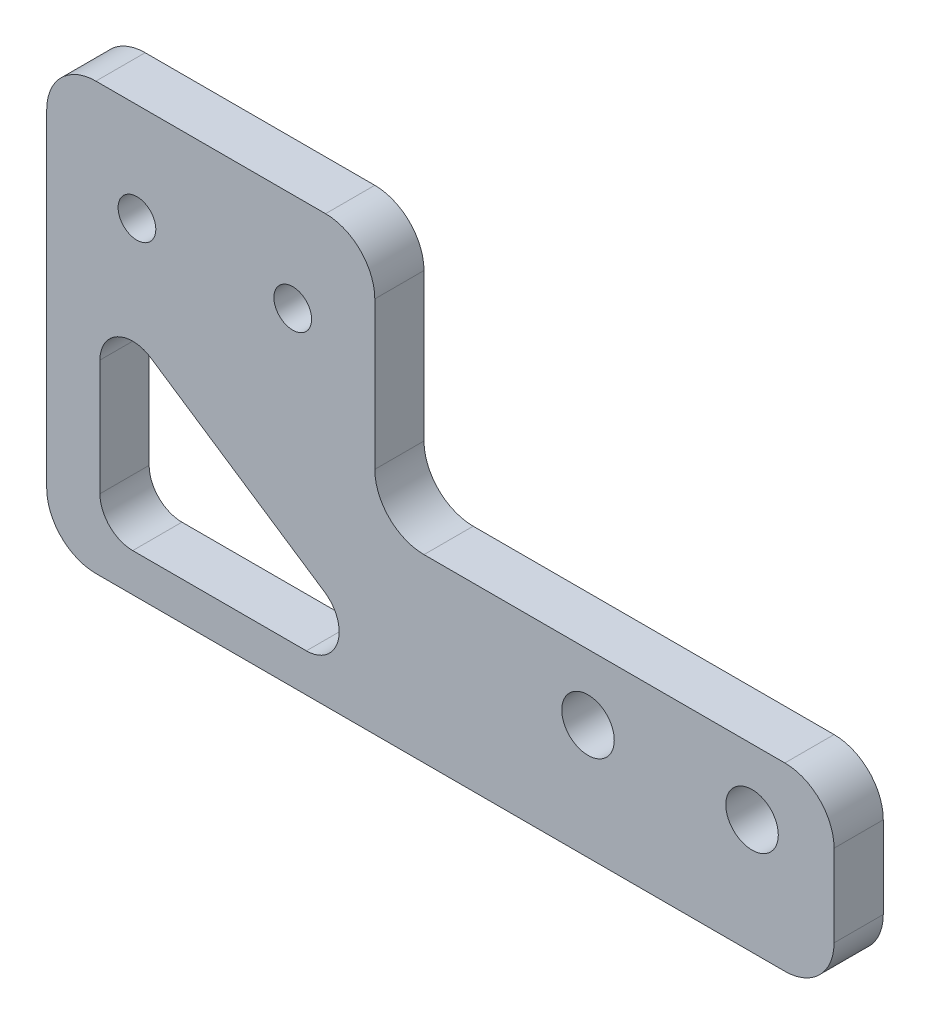
from build123d import *

# Parameters (mm, degrees)
SKETCH_1_W          = 48
SKETCH_1_H          = 67.5
SKETCH_1_R          = 1.6
SKETCH_1_R_2        = 1.15
EXTRUDE_1_DEPTH     = 3
SKETCH_3_W          = 28
SKETCH_3_H          = 56.5
CUT_EXTRUDE_1_DEPTH = 4
FILLET_1_R          = 3
SKETCH_5_W          = 37.363309984
SKETCH_5_H          = 43.840284148
CUT_EXTRUDE_2_DEPTH = 10
FILLET_2_R          = 3
CUT_EXTRUDE_3_DEPTH = 10
FILLET_3_R          = 2


with BuildPart() as part:
    # 草图1 → 凸台-拉伸1 (new body)
    with BuildSketch(Plane.XY):
        with Locations((24, 33.75)):
            Rectangle(SKETCH_1_W, SKETCH_1_H)
        with Locations((33, 7)):
            Circle(SKETCH_1_R, mode=Mode.SUBTRACT)
        with Locations((43, 7)):
            Circle(SKETCH_1_R, mode=Mode.SUBTRACT)
        with Locations((5.5, 20)):
            Circle(SKETCH_1_R_2, mode=Mode.SUBTRACT)
        with Locations((15, 20)):
            Circle(SKETCH_1_R_2, mode=Mode.SUBTRACT)
    extrude(amount=EXTRUDE_1_DEPTH)

    # 草图3 → 切除-拉伸1 (cut, through all)
    with BuildSketch(Plane.XY.offset(3)):
        with Locations((34, 39.25)):
            Rectangle(SKETCH_3_W, SKETCH_3_H)
    extrude(amount=-CUT_EXTRUDE_1_DEPTH, mode=Mode.SUBTRACT)

    # 圆角1
    fillet_1_edges = [part.edges().sort_by_distance(p)[0] for p in [
        (48, 11, 1.5),
        (20, 11, 1.5),
        (20, 67.5, 1.5),
        (0, 67.5, 1.5),
        (48, 0, 1.5),
        (0, 0, 1.5),
    ]]
    fillet(fillet_1_edges, radius=FILLET_1_R)

    # 草图5 → 切除-拉伸2 (cut)
    with BuildSketch(Plane.XY.offset(3)):
        with Locations((12.934999088, 47.920142074)):
            Rectangle(SKETCH_5_W, SKETCH_5_H)
    extrude(amount=-CUT_EXTRUDE_2_DEPTH, mode=Mode.SUBTRACT)

    # 圆角2
    fillet_2_edges = [part.edges().sort_by_distance(p)[0] for p in [
        (20, 26, 1.5),
        (0, 26, 1.5),
    ]]
    fillet(fillet_2_edges, radius=FILLET_2_R)

    # 草图6 → 切除-拉伸3 (cut)
    with BuildSketch(Plane.XY.offset(3)):
        Polygon((3.243199116, 15.127643762), (3.243199116, 2.334759345), (22.435417019, 2.334759345), align=None)
    extrude(amount=-CUT_EXTRUDE_3_DEPTH, mode=Mode.SUBTRACT)

    # 圆角3
    fillet_3_edges = [part.edges().sort_by_distance(p)[0] for p in [
        (3.243199116, 15.127643762, 1.5),
        (22.435417019, 2.334759345, 1.5),
        (3.243199116, 2.334759345, 1.5),
    ]]
    fillet(fillet_3_edges, radius=FILLET_3_R)


solid = part.part
